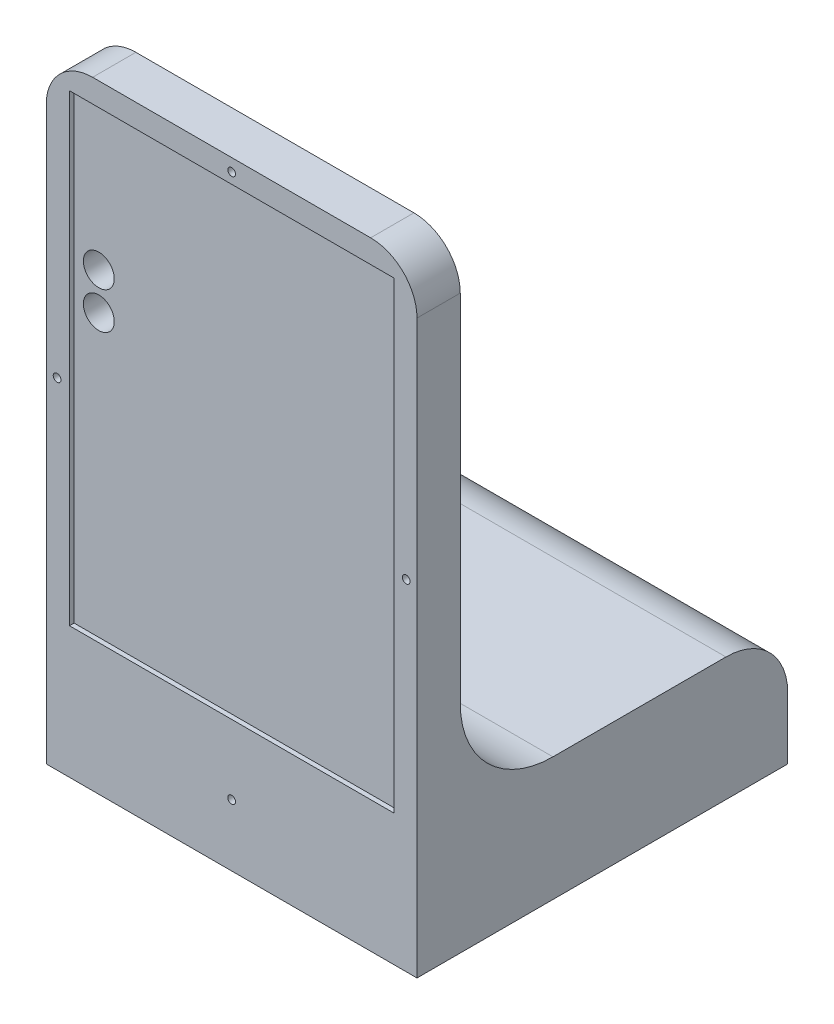
from build123d import *

# Parameters (mm, degrees)
ESQUISSE1_W                  = 120
ESQUISSE1_H                  = 200
BOSS_EXTRU_2_DEPTH           = 25
ESQUISSE3_W                  = 120
ESQUISSE3_H                  = 40
BOSS_EXTRU_3_DEPTH           = 70
CONG_1_R                     = 15
ESQUISSE4_W                  = 120
ESQUISSE4_H                  = 40
BOSS_EXTRU_4_DEPTH           = 140
CONG_2_R                     = 30
ESQUISSE5_W                  = 50
ESQUISSE5_H                  = 30
BOSS_EXTRU_9_DEPTH           = 7.5
ESQUISSE7_W                  = 100
ESQUISSE7_H                  = 80
ENL_V_MAT_EXTRU_1_DEPTH      = 35
ENL_V_MAT_EXTRU_7_REACH      = 262
ESQUISSE8_R                  = 7.5
ESQUISSE12_W                 = 50
ESQUISSE12_H                 = 30
ENL_V_MAT_EXTRU_8_DEPTH      = 5
ESQUISSE13_R                 = 12.5
ENL_V_MAT_EXTRU_9_DEPTH      = 1
ENL_V_MAT_EXTRU_9_DEPTH_BACK = 121
ESQUISSE14_W                 = 15
ESQUISSE14_H                 = 5
ENL_V_MAT_EXTRU_10_DEPTH     = 3
ESQUISSE22_W                 = 142.933359841
ESQUISSE22_H                 = 230.615168818
ENL_V_MAT_EXTRU_12_DEPTH     = 141
ESQUISSE23_W                 = 105
ESQUISSE23_H                 = 150
ENL_V_MAT_EXTRU_13_DEPTH     = 12.5
ESQUISSE24_R                 = 1.25
ENL_V_MAT_EXTRU_14_DEPTH     = 5
CONG_4_R                     = 15
ESQUISSE25_W                 = 11
ESQUISSE25_H                 = 200
ENL_V_MAT_EXTRU_15_DEPTH     = 121
ESQUISSE26_R                 = 5
ENL_V_MAT_EXTRU_16_DEPTH     = 11
ESQUISSE28_W                 = 34
ESQUISSE28_H                 = 40
ENL_V_MAT_EXTRU_17_DEPTH     = 121
CONG_5_R                     = 20
ESQUISSE29_R                 = 1.25
ENL_V_MAT_EXTRU_18_DEPTH     = 4
ESQUISSE30_R                 = 1.25
ENL_V_MAT_EXTRU_19_DEPTH     = 121


with BuildPart() as part:
    # Esquisse1 → Boss.-Extru.2 (new body, symmetric)
    with BuildSketch(Plane.XY):
        with Locations((60, 100)):
            Rectangle(ESQUISSE1_W, ESQUISSE1_H)
    extrude(amount=BOSS_EXTRU_2_DEPTH, both=True)

    # Esquisse3 → Boss.-Extru.3 (add)
    with BuildSketch(Plane.XY.offset(25)):
        with Locations((60, 20)):
            Rectangle(ESQUISSE3_W, ESQUISSE3_H)
    extrude(amount=BOSS_EXTRU_3_DEPTH)

    # Congé1
    cong_1_edges = [part.edges().sort_by_distance(p)[0] for p in [
        (60, 40, 25),
    ]]
    fillet(cong_1_edges, radius=CONG_1_R)

    # Esquisse4 → Boss.-Extru.4 (add)
    with BuildSketch(Plane(origin=(0, 0, -25), x_dir=(-1, 0, 0), z_dir=(0, 0, -1))):
        with Locations((-60, 20)):
            Rectangle(ESQUISSE4_W, ESQUISSE4_H)
    extrude(amount=BOSS_EXTRU_4_DEPTH)

    # Congé2
    cong_2_edges = [part.edges().sort_by_distance(p)[0] for p in [
        (60, 40, -25),
    ]]
    fillet(cong_2_edges, radius=CONG_2_R)

    # Esquisse5 → Boss.-Extru.9 (add)
    with BuildSketch(Plane.XY.offset(95)):
        with Locations((60, 20)):
            Rectangle(ESQUISSE5_W, ESQUISSE5_H)
    extrude(amount=-BOSS_EXTRU_9_DEPTH)

    # Esquisse7 → Enlèv. mat.-Extru.1 (cut)
    with BuildSketch(Plane.XZ):
        with Locations((60, 45)):
            Rectangle(ESQUISSE7_W, ESQUISSE7_H)
    extrude(amount=-ENL_V_MAT_EXTRU_1_DEPTH, mode=Mode.SUBTRACT)

    # Esquisse8 → Enlèv. mat.-Extru.7 (cut, up to next)
    with BuildSketch(Plane.XY.offset(95), mode=Mode.PRIVATE) as enl_v_mat_extru_7_sk1:
        with Locations((47.5, 20)):
            Circle(ESQUISSE8_R)
    enl_v_mat_extru_7_tool1 = extrude(enl_v_mat_extru_7_sk1.sketch, amount=-ENL_V_MAT_EXTRU_7_REACH, mode=Mode.PRIVATE) & part.part
    add(enl_v_mat_extru_7_tool1.solids().sort_by_distance((47.5, 20, 95))[0], mode=Mode.SUBTRACT)
    # Esquisse8 → Enlèv. mat.-Extru.7 (cut, up to next)
    with BuildSketch(Plane.XY.offset(95), mode=Mode.PRIVATE) as enl_v_mat_extru_7_sk2:
        with Locations((72.5, 20)):
            Circle(ESQUISSE8_R)
    enl_v_mat_extru_7_tool2 = extrude(enl_v_mat_extru_7_sk2.sketch, amount=-ENL_V_MAT_EXTRU_7_REACH, mode=Mode.PRIVATE) & part.part
    add(enl_v_mat_extru_7_tool2.solids().sort_by_distance((72.5, 20, 95))[0], mode=Mode.SUBTRACT)

    # Esquisse12 → Enlèv. mat.-Extru.8 (cut)
    with BuildSketch(Plane(origin=(0, 0, 85), x_dir=(-1, 0, 0), z_dir=(0, 0, -1))):
        with Locations((-60, 20)):
            Rectangle(ESQUISSE12_W, ESQUISSE12_H)
    extrude(amount=-ENL_V_MAT_EXTRU_8_DEPTH, mode=Mode.SUBTRACT)

    # Esquisse13 → Enlèv. mat.-Extru.9 (cut, two sides)
    with BuildSketch(Plane(origin=(120, 0, 0), x_dir=(0, 0, -1), z_dir=(1, 0, 0))) as enl_v_mat_extru_9_sk:
        with Locations((-60, 20)):
            Circle(ESQUISSE13_R)
    extrude(amount=ENL_V_MAT_EXTRU_9_DEPTH, mode=Mode.SUBTRACT)
    extrude(enl_v_mat_extru_9_sk.sketch, amount=-ENL_V_MAT_EXTRU_9_DEPTH_BACK, mode=Mode.SUBTRACT)

    # Esquisse14 → Enlèv. mat.-Extru.10 (cut)
    with BuildSketch(Plane(origin=(0, 0, 85), x_dir=(-1, 0, 0), z_dir=(0, 0, -1))):
        with Locations((-60, 2.5)):
            Rectangle(ESQUISSE14_W, ESQUISSE14_H)
    extrude(amount=-ENL_V_MAT_EXTRU_10_DEPTH, mode=Mode.SUBTRACT)

    # Esquisse22 → Enlèv. mat.-Extru.12 (cut)
    with BuildSketch(Plane.XY):
        with Locations((64.967602161, 91.924485341)):
            Rectangle(ESQUISSE22_W, ESQUISSE22_H)
    extrude(amount=ENL_V_MAT_EXTRU_12_DEPTH, mode=Mode.SUBTRACT)

    # Esquisse23 → Enlèv. mat.-Extru.13 (cut)
    with BuildSketch(Plane.XY):
        with Locations((60, 117.5)):
            Rectangle(ESQUISSE23_W, ESQUISSE23_H)
    extrude(amount=-ENL_V_MAT_EXTRU_13_DEPTH, mode=Mode.SUBTRACT)

    # Esquisse24 → Enlèv. mat.-Extru.14 (cut)
    with BuildSketch(Plane(origin=(0, 0, 0), x_dir=(-1, 0, 0), z_dir=(0, -1, 0))):
        with Locations((-76.322658076, 105)):
            Circle(ESQUISSE24_R)
        with Locations((-46.322658076, 105)):
            Circle(ESQUISSE24_R)
        with Locations((-45, 85)):
            Circle(ESQUISSE24_R)
        with Locations((-75, 85)):
            Circle(ESQUISSE24_R)
    extrude(amount=-ENL_V_MAT_EXTRU_14_DEPTH, mode=Mode.SUBTRACT)

    # Congé4
    cong_4_edges = [part.edges().sort_by_distance(p)[0] for p in [
        (120, 200, -12.5),
        (0, 200, -12.5),
        (60, 40, -165),
    ]]
    fillet(cong_4_edges, radius=CONG_4_R)

    # Esquisse25 → Enlèv. mat.-Extru.15 (cut, through all)
    with BuildSketch(Plane(origin=(0, 0, 0), x_dir=(0, 0, -1), z_dir=(1, 0, 0))):
        with Locations((5.5, 100)):
            Rectangle(ESQUISSE25_W, ESQUISSE25_H)
    extrude(amount=ENL_V_MAT_EXTRU_15_DEPTH, mode=Mode.SUBTRACT)

    # Esquisse26 → Enlèv. mat.-Extru.16 (cut)
    with BuildSketch(Plane.XY.offset(-12.5)):
        with Locations((15.5, 145.5)):
            Circle(ESQUISSE26_R)
        with Locations((15.5, 133.5)):
            Circle(ESQUISSE26_R)
    extrude(amount=-ENL_V_MAT_EXTRU_16_DEPTH, mode=Mode.SUBTRACT)

    # Esquisse28 → Enlèv. mat.-Extru.17 (cut, through all)
    with BuildSketch(Plane(origin=(120, 0, 0), x_dir=(0, 0, -1), z_dir=(1, 0, 0))):
        with Locations((148, 20)):
            Rectangle(ESQUISSE28_W, ESQUISSE28_H)
    extrude(amount=-ENL_V_MAT_EXTRU_17_DEPTH, mode=Mode.SUBTRACT)

    # Congé5
    cong_5_edges = [part.edges().sort_by_distance(p)[0] for p in [
        (60, 40, -131),
    ]]
    fillet(cong_5_edges, radius=CONG_5_R)

    # Esquisse29 → Enlèv. mat.-Extru.18 (cut)
    with BuildSketch(Plane.XY.offset(-11)):
        with Locations((60, 20)):
            Circle(ESQUISSE29_R)
    extrude(amount=-ENL_V_MAT_EXTRU_18_DEPTH, mode=Mode.SUBTRACT)

    # Esquisse30 → Enlèv. mat.-Extru.19 (cut, through all)
    with BuildSketch(Plane.XY.offset(-11)):
        with Locations((3.5, 110)):
            Circle(ESQUISSE30_R)
        with Locations((116.5, 110)):
            Circle(ESQUISSE30_R)
        with Locations((60, 195.964841854)):
            Circle(ESQUISSE30_R)
    extrude(amount=-ENL_V_MAT_EXTRU_19_DEPTH, mode=Mode.SUBTRACT)


solid = part.part
